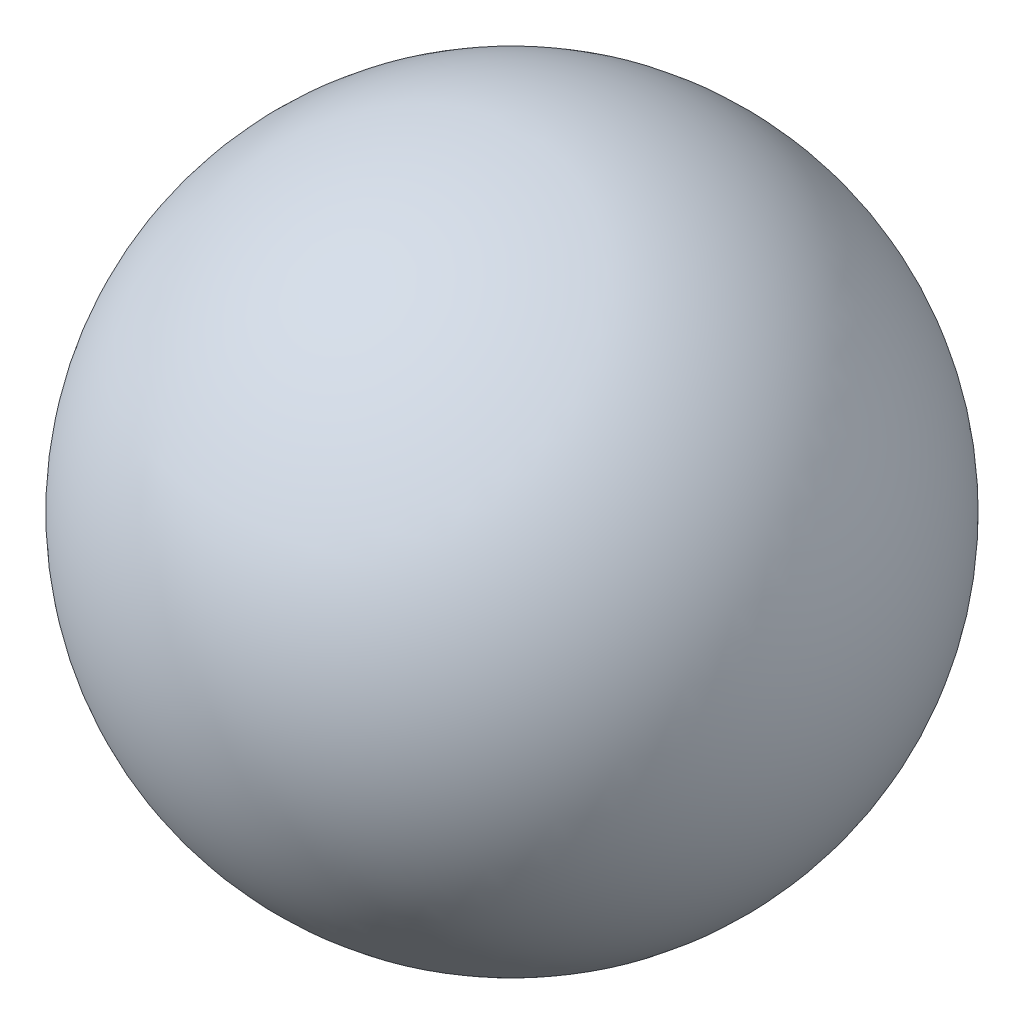
from build123d import *


with BuildPart() as part:
    # Sketch1 → Revolve5 (revolve)
    with BuildSketch(Plane.XY):
        with BuildLine():
            Line((0, -21.5), (0, 21.5))
            ThreePointArc((0, 21.5), (-21.5, 0), (0, -21.5))
        make_face()
    revolve(axis=Axis((0, -30.125069071, 0), (0, 1, 0)))


solid = part.part
